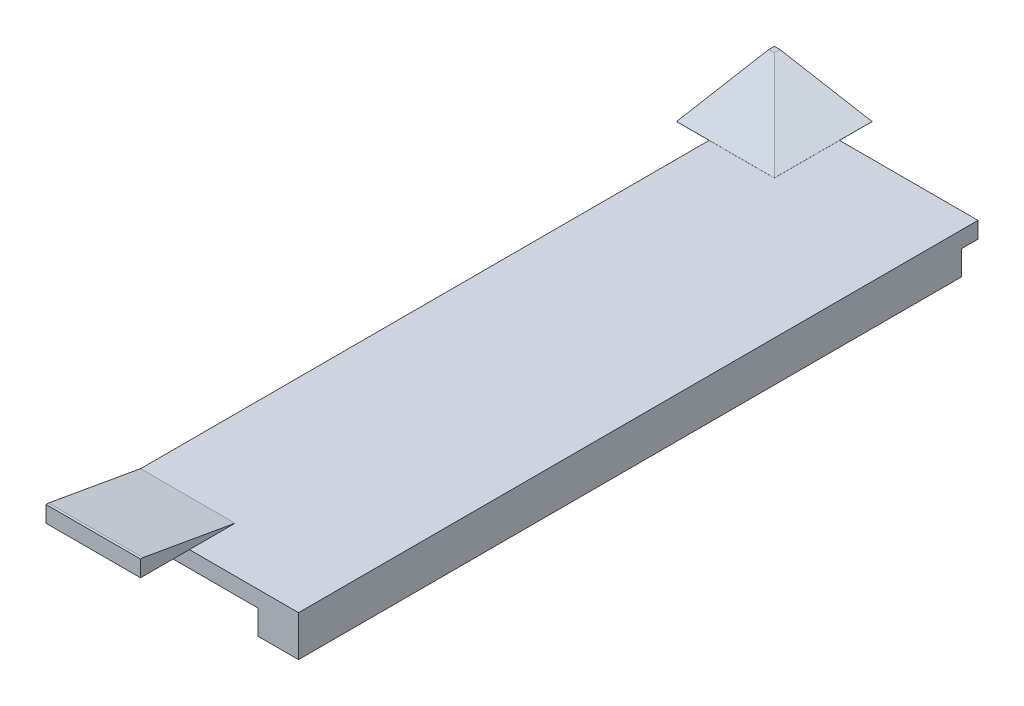
from build123d import *

# Parameters (mm, degrees)
SKETCH1_W             = 25
SKETCH1_H             = 83.4
BOSS_EXTRUDE1_DEPTH   = 2
SKETCH2_W             = 11.6
SKETCH2_H             = 11.6
SKETCH2_W_2           = 12
SKETCH2_H_2           = 12
BOSS_EXTRUDE2_DEPTH   = 2
CHAMFER1_SIZE         = 11.3
CHAMFER1_SIZE2        = 1.992494882
CHAMFER1_PART_2_SIZE  = 11.3
CHAMFER1_PART_2_SIZE2 = 1.992494882
SKETCH4_W             = 5
SKETCH4_H             = 81.4
BOSS_EXTRUDE3_DEPTH   = 3


with BuildPart() as part:
    # Sketch1 → Boss-Extrude1 (new body)
    with BuildSketch(Plane(origin=(0, 0, 0), x_dir=(1, 0, 0), z_dir=(0, 1, 0))):
        with Locations((12.5, 41.7)):
            Rectangle(SKETCH1_W, SKETCH1_H)
    extrude(amount=BOSS_EXTRUDE1_DEPTH)

    # Sketch2 → Boss-Extrude2 (add)
    with BuildSketch(Plane(origin=(0, 2, 0), x_dir=(1, 0, 0), z_dir=(0, 1, 0))):
        with Locations((5.8, -0.2)):
            Rectangle(SKETCH2_W, SKETCH2_H)
        with Locations((2, 81.4)):
            Rectangle(SKETCH2_W_2, SKETCH2_H_2)
    extrude(amount=BOSS_EXTRUDE2_DEPTH)

    # Chamfer1
    chamfer1_edges = [part.edges().sort_by_distance(p)[0] for p in [
        (5.8, 4, -5.6),
    ]]
    chamfer1_side = [part.faces().sort_by_distance(p)[0] for p in [
        (5.8, 4, 0.2),
    ]]
    chamfer(chamfer1_edges, length=CHAMFER1_SIZE, length2=CHAMFER1_SIZE2, reference=chamfer1_side[0])

    # Chamfer1 part 2
    chamfer1_part_2_edges = [part.edges().sort_by_distance(p)[0] for p in [
        (8, 4, -81.4),
        (2, 4, -75.4),
    ]]
    chamfer1_part_2_side = [part.faces().sort_by_distance(p)[0] for p in [
        (2, 4, -81.4),
    ]]
    chamfer(chamfer1_part_2_edges, length=CHAMFER1_PART_2_SIZE, length2=CHAMFER1_PART_2_SIZE2, reference=chamfer1_part_2_side[0])

    # Sketch4 → Boss-Extrude3 (add)
    with BuildSketch(Plane.XZ):
        with Locations((22.5, -40.7)):
            Rectangle(SKETCH4_W, SKETCH4_H)
    extrude(amount=BOSS_EXTRUDE3_DEPTH)


solid = part.part
